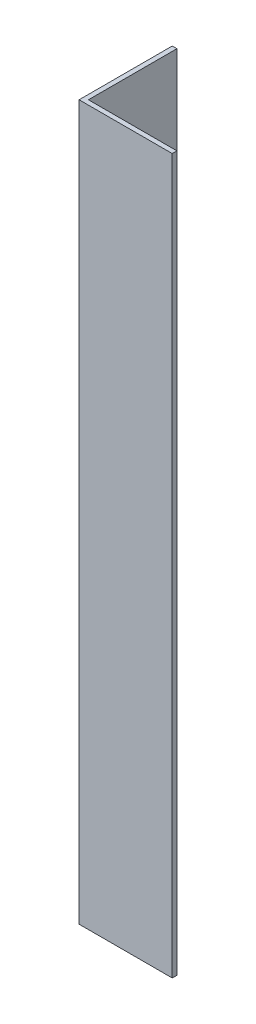
from build123d import *

# Parameters (mm, degrees)
EXTRUDE_1_DEPTH = 115


with BuildPart() as part:
    # Эскиз1 → Бобышка-Вытянуть1 (new body)
    with BuildSketch(Plane(origin=(0, 0, 0), x_dir=(1, 0, 0), z_dir=(0, 1, 0))):
        Polygon((0, 0), (0, 15), (0.75, 15), (0.75, 0.75), (15, 0.75), (15, 0), align=None)
    extrude(amount=EXTRUDE_1_DEPTH)


solid = part.part
